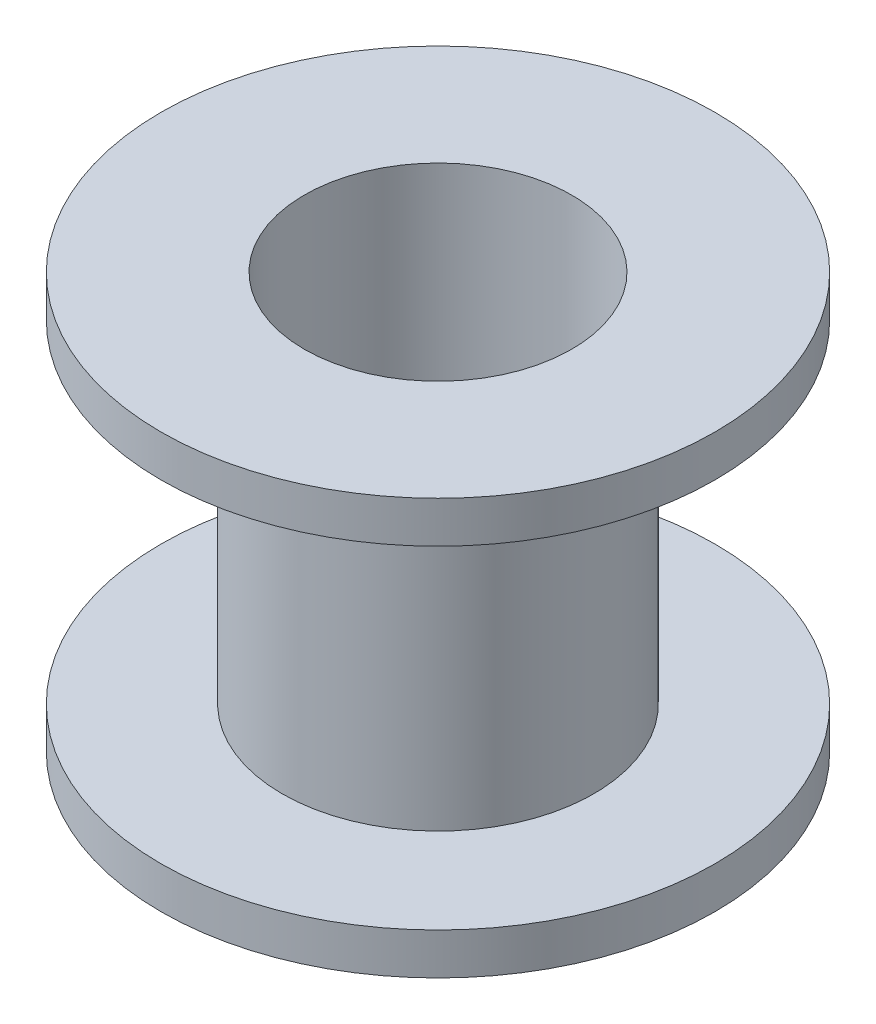
from build123d import *

# Parameters (mm, degrees)
SKETCH1_R           = 5.626
SKETCH1_R_2         = 4.826
BOSS_EXTRUDE1_DEPTH = 7.5
SKETCH2_R           = 10
SKETCH2_R_2         = 5.626
BOSS_EXTRUDE2_DEPTH = 1.5


with BuildPart() as part:
    # Sketch1 → Boss-Extrude1 (new body, symmetric)
    with BuildSketch(Plane(origin=(0, 0, 0), x_dir=(1, 0, 0), z_dir=(0, 1, 0))):
        Circle(SKETCH1_R)
        Circle(SKETCH1_R_2, mode=Mode.SUBTRACT)
    extrude(amount=BOSS_EXTRUDE1_DEPTH, both=True)

    # Sketch2 → Boss-Extrude2 (add)
    with BuildSketch(Plane(origin=(0, 7.5, 0), x_dir=(1, 0, 0), z_dir=(0, 1, 0))):
        Circle(SKETCH2_R)
        Circle(SKETCH2_R_2, mode=Mode.SUBTRACT)
    boss_extrude2 = extrude(amount=-BOSS_EXTRUDE2_DEPTH)

    # Mirror1: Boss-Extrude2 across plane
    add(boss_extrude2.mirror(Plane.ZX))


solid = part.part
